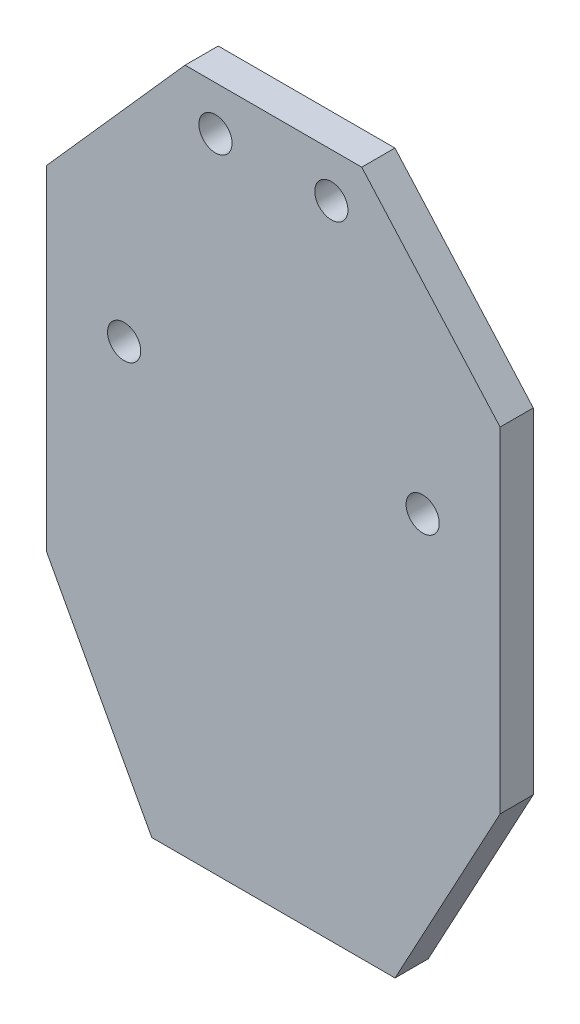
from build123d import *

# Parameters (mm, degrees)
SKETCH_1_R      = 1.5
EXTRUDE_1_DEPTH = 3


with BuildPart() as part:
    # 草图1 → 凸台-拉伸1 (new body)
    with BuildSketch(Plane.XY):
        Polygon((11, 0), (-11, 0), (-20.5, 17.599715907), (-20.5, 47.899715907), (-7.989824602, 62), (7.989824602, 62), (20.5, 47.899715907), (20.5, 17.599715907), align=None)
        with Locations((-5.239824602, 58)):
            Circle(SKETCH_1_R, mode=Mode.SUBTRACT)
        with Locations((-13.5, 37.599715907)):
            Circle(SKETCH_1_R, mode=Mode.SUBTRACT)
        with Locations((13.5, 37.599715907)):
            Circle(SKETCH_1_R, mode=Mode.SUBTRACT)
        with Locations((5.239824602, 58)):
            Circle(SKETCH_1_R, mode=Mode.SUBTRACT)
    extrude(amount=EXTRUDE_1_DEPTH)


solid = part.part
